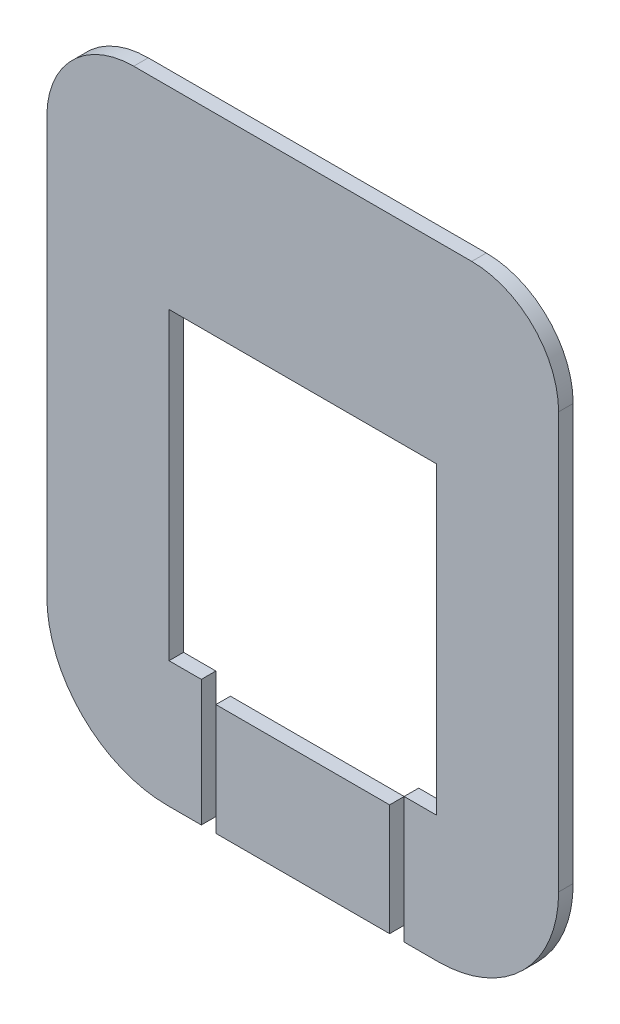
from build123d import *

# Parameters (mm, degrees)
BOSS_EXTRUDE1_DEPTH = 4.3
SKETCH2_W           = 79.11
SKETCH2_H           = 90
SKETCH2_W_2         = 4.3
SKETCH2_H_2         = 33.01
CUT_EXTRUDE1_DEPTH  = 10


with BuildPart() as part:
    # Sketch1 → Boss-Extrude1 (new body)
    with BuildSketch(Plane.XY):
        with BuildLine():
            Line((0.5, -92.2), (40, -92.2))
            ThreePointArc((40, -92.2), (65.243712088, -81.743712088), (75.7, -56.5))
            Line((75.7, -56.5), (75.7, 66.5))
            ThreePointArc((75.7, 66.5), (68.172644276, 84.672644276), (50, 92.2))
            Line((50, 92.2), (-50, 92.2))
            ThreePointArc((-50, 92.2), (-68.172644276, 84.672644276), (-75.7, 66.5))
            Line((-75.7, 66.5), (-75.7, -56.5))
            ThreePointArc((-75.7, -56.5), (-65.243712088, -81.743712088), (-40, -92.2))
            Line((-40, -92.2), (-0.5, -92.2))
            Line((-0.5, -92.2), (0.5, -92.2))
        make_face()
    extrude(amount=BOSS_EXTRUDE1_DEPTH)

    # Sketch2 → Cut-Extrude1 (cut)
    with BuildSketch(Plane.XY.offset(4.3)):
        with Locations((0, -9.89)):
            Rectangle(SKETCH2_W, SKETCH2_H)
        Polygon((30, -54.89), (-30, -54.89), (-30, -59.19), (-25.7, -59.19), (25.7, -59.19), (30, -59.19), align=None)
        with Locations((-27.85, -75.695)):
            Rectangle(SKETCH2_W_2, SKETCH2_H_2)
        with Locations((27.85, -75.695)):
            Rectangle(SKETCH2_W_2, SKETCH2_H_2)
    extrude(amount=-CUT_EXTRUDE1_DEPTH, mode=Mode.SUBTRACT)


solid = part.part
